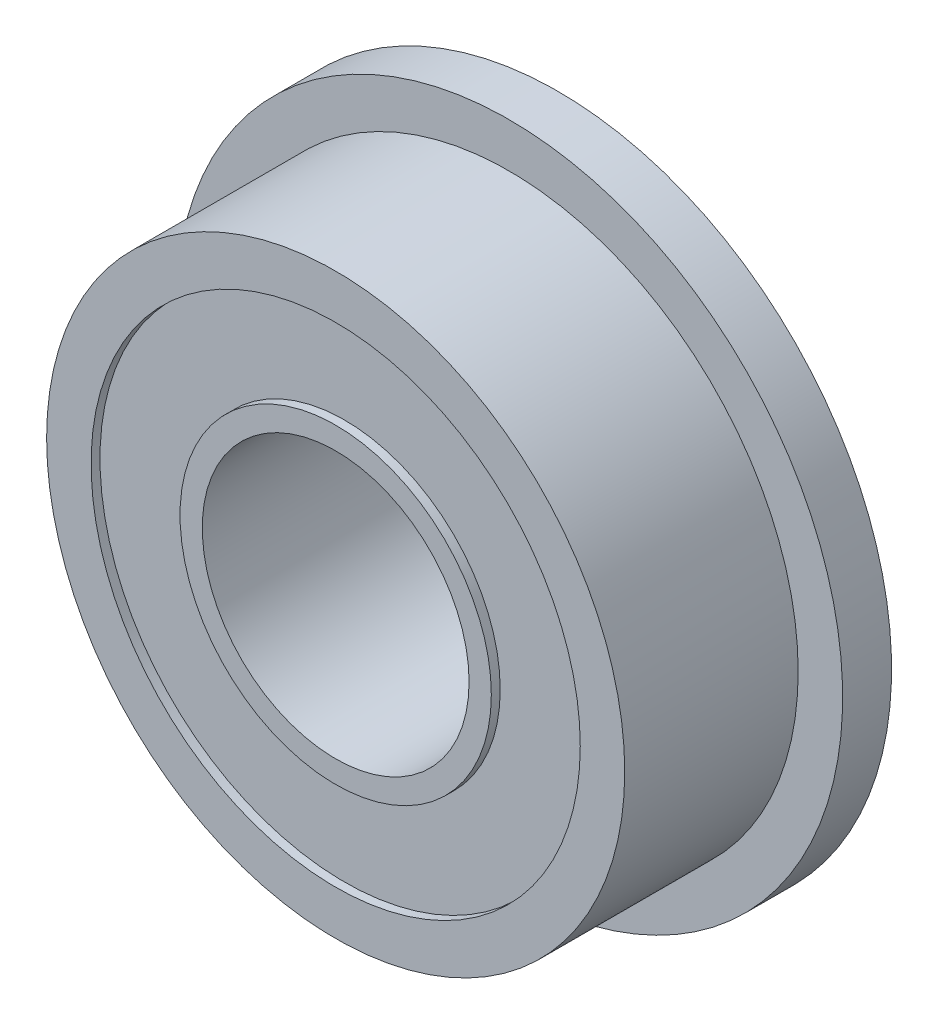
from build123d import *

# Parameters (mm, degrees)
SKETCH_1_R          = 6.5
EXTRUDE_1_DEPTH     = 2.5
SKETCH_4_R          = 7.5
EXTRUDE_2_DEPTH     = 1.1
SKETCH_2_R          = 3
CUT_EXTRUDE_1_DEPTH = 6
SKETCH_3_R          = 5.5
SKETCH_3_R_2        = 3.5
CUT_EXTRUDE_2_DEPTH = 0.2


with BuildPart() as part:
    # 草圖1 → 填料-伸長1 (new body, symmetric)
    with BuildSketch(Plane.XY):
        Circle(SKETCH_1_R)
    extrude(amount=EXTRUDE_1_DEPTH, both=True)

    # 草圖4 → 填料-伸長2 (add)
    with BuildSketch(Plane(origin=(0, 0, -2.5), x_dir=(-1, 0, 0), z_dir=(0, 0, -1))):
        Circle(SKETCH_4_R)
    extrude(amount=-EXTRUDE_2_DEPTH)

    # 草圖2 → 除料-伸長1 (cut, through all)
    with BuildSketch(Plane.XY.offset(2.5)):
        Circle(SKETCH_2_R)
    extrude(amount=-CUT_EXTRUDE_1_DEPTH, mode=Mode.SUBTRACT)

    # 草圖3 → 除料-伸長2 (cut)
    with BuildSketch(Plane.XY.offset(2.5)):
        Circle(SKETCH_3_R)
        Circle(SKETCH_3_R_2, mode=Mode.SUBTRACT)
    cut_extrude_2 = extrude(amount=-CUT_EXTRUDE_2_DEPTH, mode=Mode.SUBTRACT)

    # 鏡射1: 除料-伸長2 across plane
    add(cut_extrude_2.mirror(Plane.XY), mode=Mode.SUBTRACT)


solid = part.part
